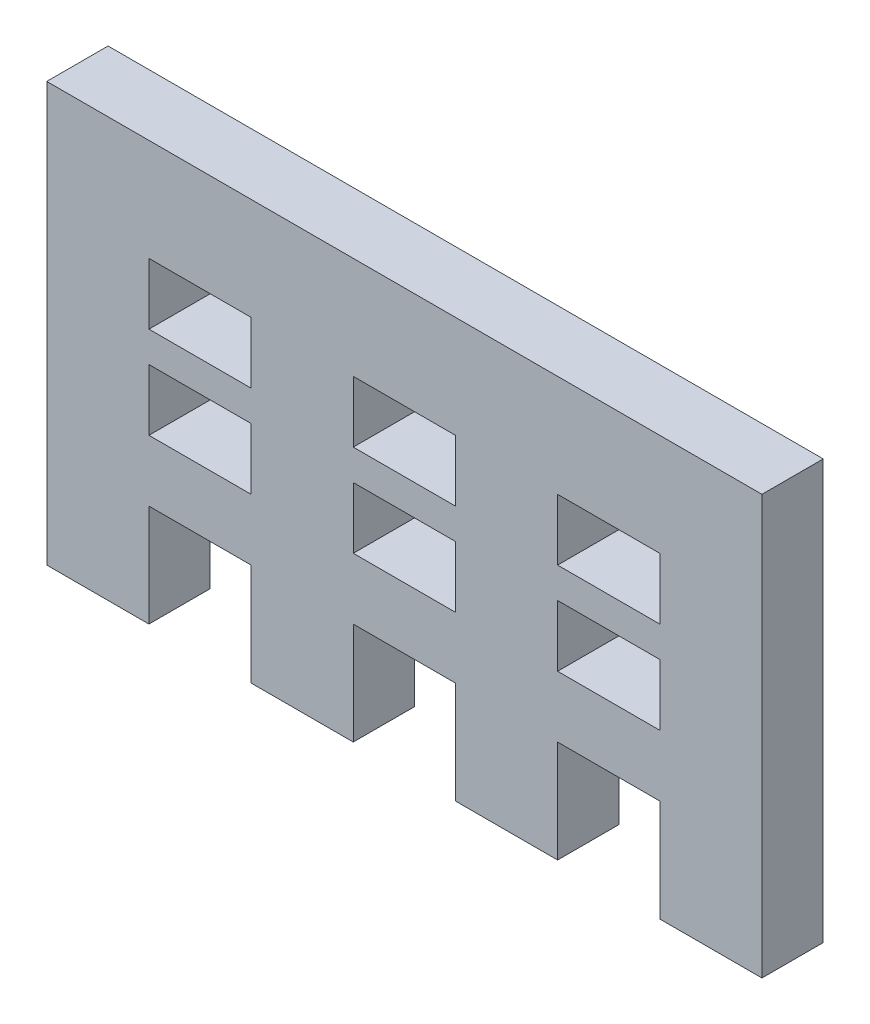
from build123d import *

# Parameters (mm, degrees)
ESQUISSE1_W        = 5
ESQUISSE1_H        = 3
BOSS_EXTRU_1_DEPTH = 3


with BuildPart() as part:
    # Esquisse1 → Boss.-Extru.1 (new body)
    with BuildSketch(Plane.XY):
        Polygon((-20, -5), (-20, 0), (-15, 0), (-15, -5), (-10, -5), (-10, 0), (-5, 0), (-5, -5), (0, -5), (0, 15.5), (-35, 15.5), (-35, -5), (-30, -5), (-30, 0), (-25, 0), (-25, -5), align=None)
        with Locations((-7.5, 9)):
            Rectangle(ESQUISSE1_W, ESQUISSE1_H, mode=Mode.SUBTRACT)
        with Locations((-17.5, 9)):
            Rectangle(ESQUISSE1_W, ESQUISSE1_H, mode=Mode.SUBTRACT)
        with Locations((-27.5, 9)):
            Rectangle(ESQUISSE1_W, ESQUISSE1_H, mode=Mode.SUBTRACT)
        with Locations((-7.5, 4.5)):
            Rectangle(ESQUISSE1_W, ESQUISSE1_H, mode=Mode.SUBTRACT)
        with Locations((-17.5, 4.5)):
            Rectangle(ESQUISSE1_W, ESQUISSE1_H, mode=Mode.SUBTRACT)
        with Locations((-27.5, 4.5)):
            Rectangle(ESQUISSE1_W, ESQUISSE1_H, mode=Mode.SUBTRACT)
    extrude(amount=BOSS_EXTRU_1_DEPTH)


solid = part.part
